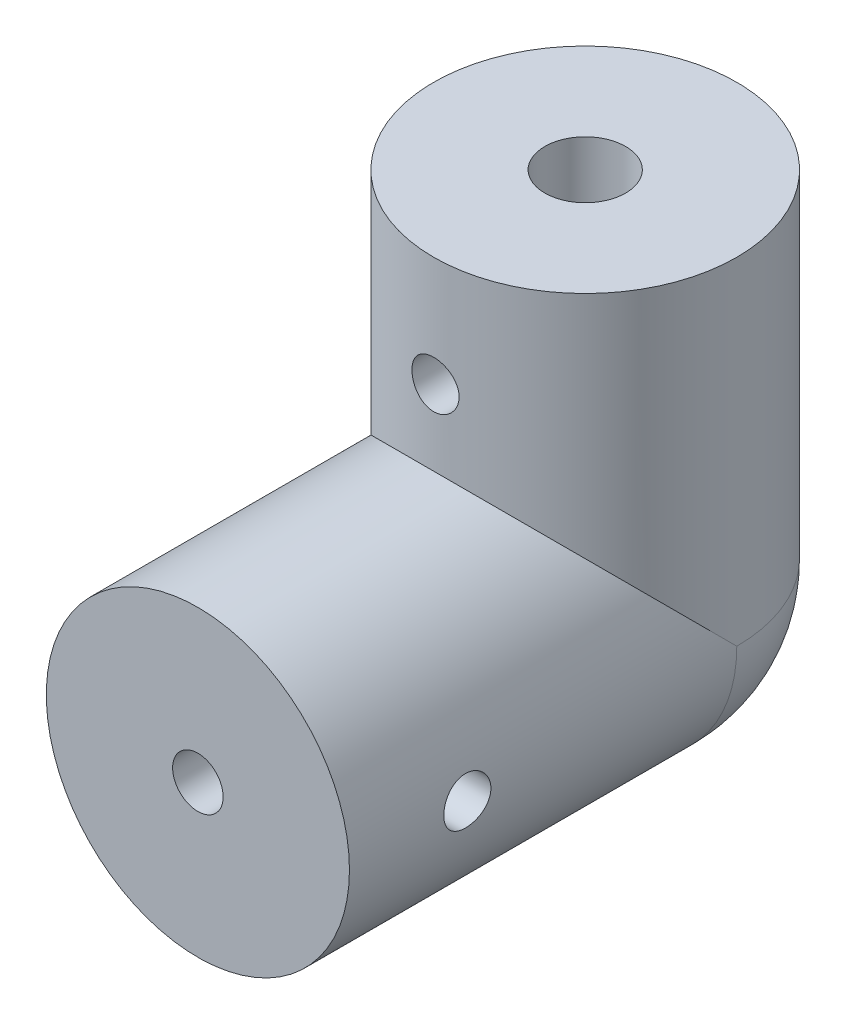
from build123d import *

# Parameters (mm, degrees)
CROQUIS1_R                   = 9
CROQUIS1_R_2                 = 1.5
SALIENTE_EXTRUIR1_DEPTH      = 15
SALIENTE_EXTRUIR1_DEPTH_BACK = 8
CROQUIS2_R                   = 9
CROQUIS2_R_2                 = 2.4
SALIENTE_EXTRUIR4_DEPTH      = 20
CROQUIS7_R                   = 2.4
CORTAR_EXTRUIR1_DEPTH        = 20
CROQUIS8_R                   = 1.5
CORTAR_EXTRUIR2_DEPTH        = 15
CROQUIS9_R                   = 1.4
CORTAR_EXTRUIR3_DEPTH        = 19
CROQUIS10_R                  = 1.4
CORTAR_EXTRUIR4_DEPTH        = 1
CORTAR_EXTRUIR4_DEPTH_BACK   = 33.0000001


with BuildPart() as part:
    # Croquis1 → Saliente-Extruir1 (new body, two sides)
    with BuildSketch(Plane.XY) as saliente_extruir1_sk:
        Circle(CROQUIS1_R)
        Circle(CROQUIS1_R_2, mode=Mode.SUBTRACT)
    extrude(amount=SALIENTE_EXTRUIR1_DEPTH)
    extrude(saliente_extruir1_sk.sketch, amount=-SALIENTE_EXTRUIR1_DEPTH_BACK)

    # Croquis2 → Saliente-Extruir4 (add)
    with BuildSketch(Plane(origin=(0, 0, 0), x_dir=(1, 0, 0), z_dir=(0, 1, 0))):
        with Locations((0, 8)):
            Circle(CROQUIS2_R)
        with Locations((0, 8)):
            Circle(CROQUIS2_R_2, mode=Mode.SUBTRACT)
    extrude(amount=SALIENTE_EXTRUIR4_DEPTH)

    # Croquis6 → Revolución4 (revolve)
    with BuildSketch(Plane(origin=(0, 0, -8), x_dir=(-1, 0, 0), z_dir=(0, 0, -1))):
        with BuildLine():
            Line((0, 0), (0, -9))
            ThreePointArc((0, -9), (-6.363961031, -6.363961031), (-9, 0))
            Line((-9, 0), (0, 0))
        make_face()
    revolve(axis=Axis((0, 0, -8), (0, -1, 0)))

    # Croquis7 → Cortar-Extruir1 (cut)
    with BuildSketch(Plane(origin=(0, 20, 0), x_dir=(1, 0, 0), z_dir=(0, 1, 0))):
        with Locations((0, 8)):
            Circle(CROQUIS7_R)
    extrude(amount=-CORTAR_EXTRUIR1_DEPTH, mode=Mode.SUBTRACT)

    # Croquis8 → Cortar-Extruir2 (cut)
    with BuildSketch(Plane.XY.offset(15)):
        Circle(CROQUIS8_R)
    extrude(amount=-CORTAR_EXTRUIR2_DEPTH, mode=Mode.SUBTRACT)

    # Croquis9 → Cortar-Extruir3 (cut, through all)
    with BuildSketch(Plane.ZY.offset(9)):
        with Locations((8, 0)):
            Circle(CROQUIS9_R)
    extrude(amount=-CORTAR_EXTRUIR3_DEPTH, mode=Mode.SUBTRACT)

    # Croquis10 → Cortar-Extruir4 (cut, two sides)
    with BuildSketch(Plane(origin=(0, 0, -17), x_dir=(-1, 0, 0), z_dir=(0, 0, -1))) as cortar_extruir4_sk:
        with Locations((0, 13.459047629)):
            Circle(CROQUIS10_R)
    extrude(amount=CORTAR_EXTRUIR4_DEPTH, mode=Mode.SUBTRACT)
    extrude(cortar_extruir4_sk.sketch, amount=-CORTAR_EXTRUIR4_DEPTH_BACK, mode=Mode.SUBTRACT)


solid = part.part
